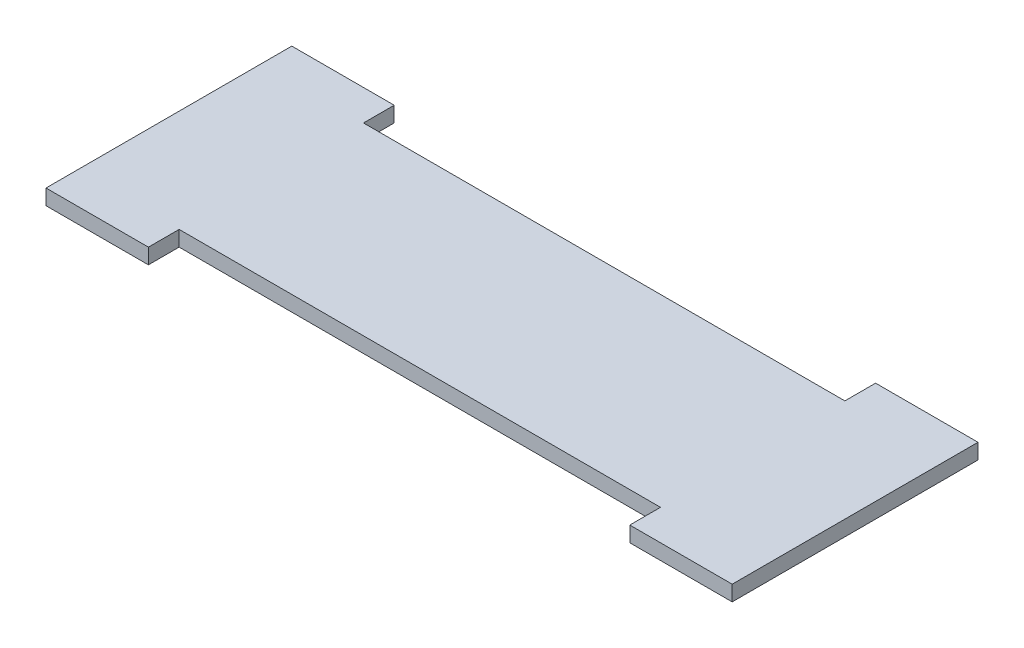
from build123d import *

# Parameters (mm, degrees)
CROQUIS1_W              = 20
CROQUIS1_H              = 6
CROQUIS1_W_2            = 134
CROQUIS1_H_2            = 36
SALIENTE_EXTRUIR1_DEPTH = 3


with BuildPart() as part:
    # Croquis1 → Saliente-Extruir1 (new body)
    with BuildSketch(Plane(origin=(0, 0, 0), x_dir=(1, 0, 0), z_dir=(0, 1, 0))):
        with Locations((10, -3)):
            Rectangle(CROQUIS1_W, CROQUIS1_H)
        with Locations((67, 18)):
            Rectangle(CROQUIS1_W_2, CROQUIS1_H_2)
        with Locations((10, 39)):
            Rectangle(CROQUIS1_W, CROQUIS1_H)
        with Locations((124, 39)):
            Rectangle(CROQUIS1_W, CROQUIS1_H)
        with Locations((124, -3)):
            Rectangle(CROQUIS1_W, CROQUIS1_H)
    extrude(amount=SALIENTE_EXTRUIR1_DEPTH)


solid = part.part
